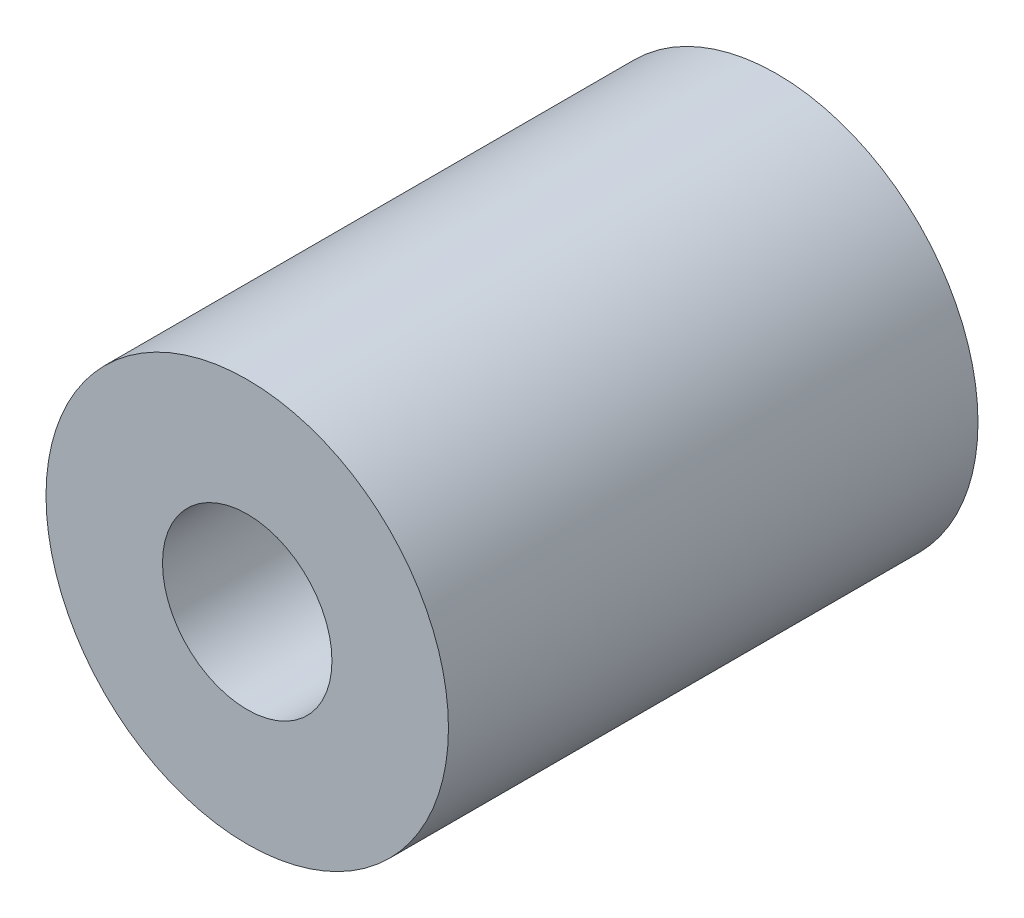
from build123d import *

# Parameters (mm, degrees)
SKETCH_1_R          = 9.5
EXTRUDE_1_DEPTH     = 25
SKETCH_2_R          = 4
CUT_EXTRUDE_1_DEPTH = 12.5
SKETCH_3_R          = 3
CUT_EXTRUDE_2_DEPTH = 12.5


with BuildPart() as part:
    # 草图1 → 凸台-拉伸1 (new body)
    with BuildSketch(Plane.XY):
        Circle(SKETCH_1_R)
    extrude(amount=EXTRUDE_1_DEPTH)

    # 草图2 → 切除-拉伸1 (cut)
    with BuildSketch(Plane.XY.offset(25)):
        Circle(SKETCH_2_R)
    extrude(amount=-CUT_EXTRUDE_1_DEPTH, mode=Mode.SUBTRACT)

    # 草图3 → 切除-拉伸2 (cut)
    with BuildSketch(Plane(origin=(0, 0, 0), x_dir=(-1, 0, 0), z_dir=(0, 0, -1))):
        Circle(SKETCH_3_R)
    extrude(amount=-CUT_EXTRUDE_2_DEPTH, mode=Mode.SUBTRACT)


solid = part.part
